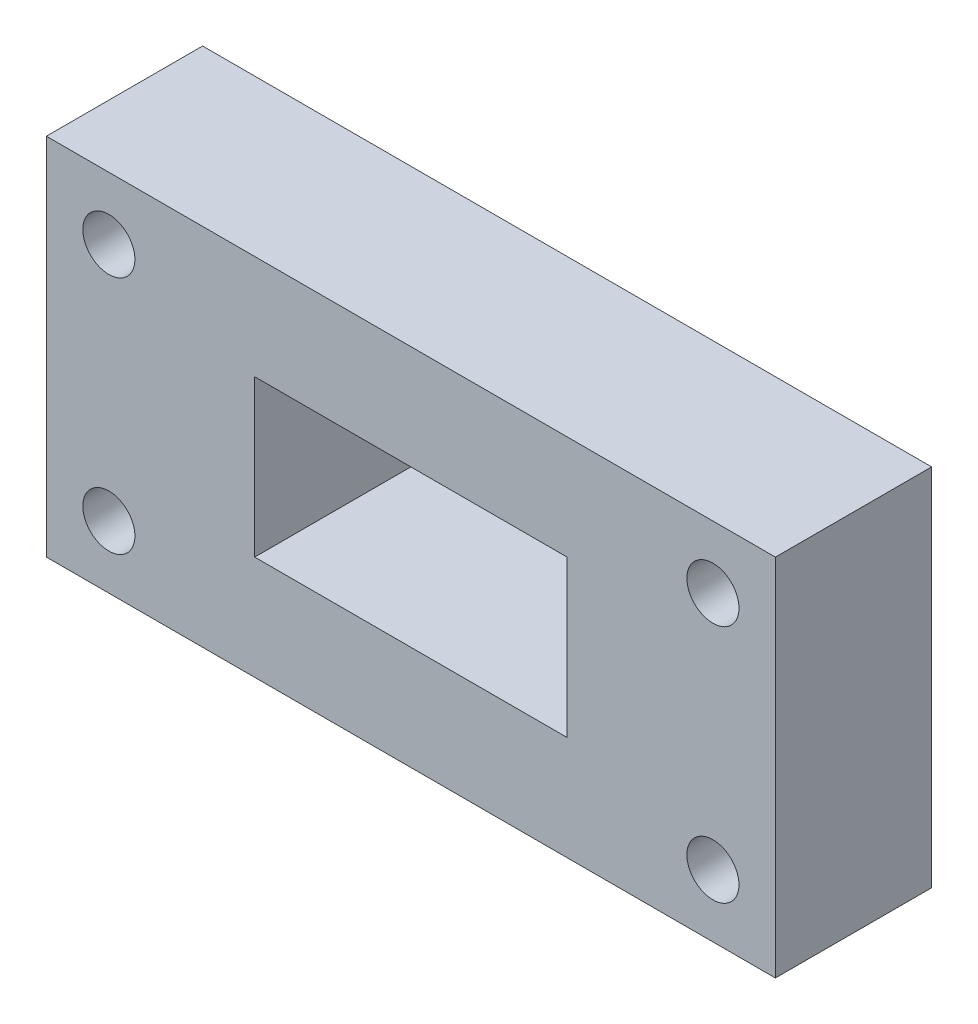
from build123d import *

# Parameters (mm, degrees)
ESBO_O1_W                = 140
ESBO_O1_H                = 70
RESSALTO_EXTRUS_O1_DEPTH = 30
ESBO_O2_W                = 60
ESBO_O2_H                = 30
CORTE_EXTRUS_O1_DEPTH    = 31
ESBO_O3_R                = 5
CORTE_EXTRUS_O3_DEPTH    = 31


with BuildPart() as part:
    # Esboço1 → Ressalto-extrusão1 (new body)
    with BuildSketch(Plane.XY):
        Rectangle(ESBO_O1_W, ESBO_O1_H)
    extrude(amount=RESSALTO_EXTRUS_O1_DEPTH)

    # Esboço2 → Corte-extrusão1 (cut, through all)
    with BuildSketch(Plane.XY.offset(30)):
        Rectangle(ESBO_O2_W, ESBO_O2_H)
    extrude(amount=-CORTE_EXTRUS_O1_DEPTH, mode=Mode.SUBTRACT)

    # Esboço3 → Corte-extrusão3 (cut, through all)
    with BuildSketch(Plane.XY.offset(30)):
        with Locations((-58, 23)):
            Circle(ESBO_O3_R)
        with Locations((58, 23)):
            Circle(ESBO_O3_R)
        with Locations((58, -23)):
            Circle(ESBO_O3_R)
        with Locations((-58, -23)):
            Circle(ESBO_O3_R)
    extrude(amount=-CORTE_EXTRUS_O3_DEPTH, mode=Mode.SUBTRACT)


solid = part.part
